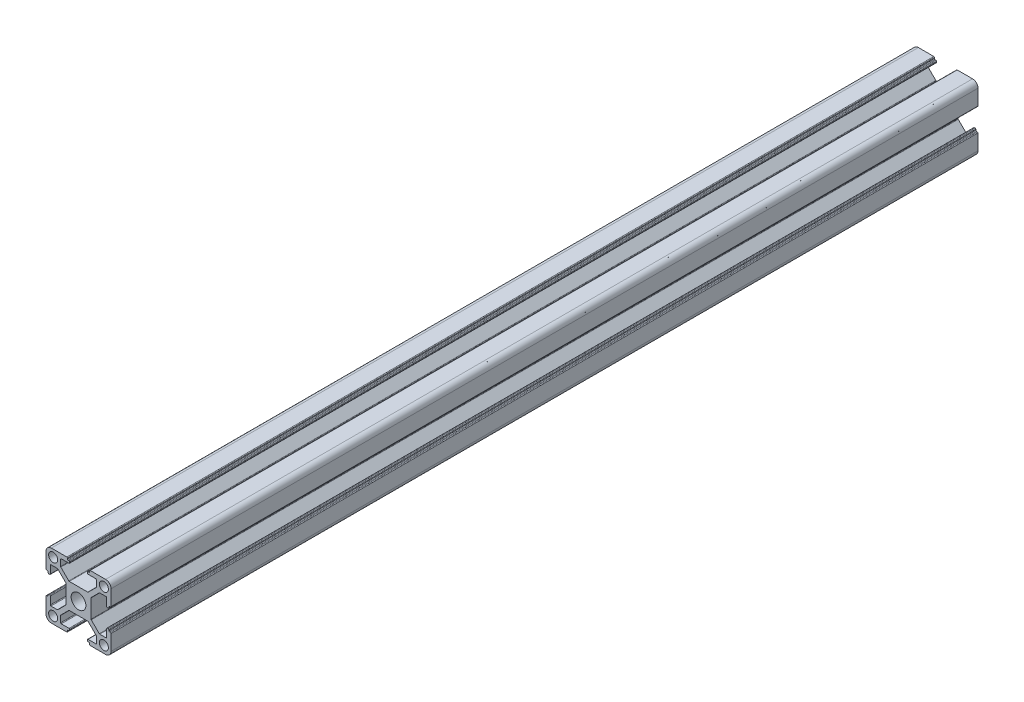
from build123d import *

# Parameters (mm, degrees)
CROQUIS1_R              = 2.1
CROQUIS1_R_2            = 3.4
SALIENTE_EXTRUIR1_DEPTH = 400


with BuildPart() as part:
    # Croquis1 → Saliente-Extruir1 (new body)
    with BuildSketch(Plane(origin=(0, 0, -50), x_dir=(-1, 0, 0), z_dir=(0, 0, -1))):
        with BuildLine():
            Line((14.7, -5.1), (14.3, -5.1))
            ThreePointArc((14.3, -5.1), (14.087867966, -5.012132034), (14, -4.8))
            Line((14, -4.8), (14, -4.4))
            ThreePointArc((14, -4.4), (13.912132034, -4.187867966), (13.7, -4.1))
            Line((13.7, -4.1), (13.3, -4.1))
            ThreePointArc((13.3, -4.1), (13.087867966, -4.187867966), (13, -4.4))
            Line((13, -4.4), (13, -7.95))
            ThreePointArc((13, -7.95), (12.912132034, -8.162132034), (12.7, -8.25))
            Line((12.7, -8.25), (9.789264108, -8.25))
            ThreePointArc((9.789264108, -8.25), (9.674477865, -8.22717164), (9.577160832, -8.162160788))
            Line((9.577160832, -8.162160788), (5.887896723, -4.473896751))
            ThreePointArc((5.887896723, -4.473896751), (5.822843922, -4.376559778), (5.8, -4.261735963))
            Line((5.8, -4.261735963), (5.8, 4.260735931))
            ThreePointArc((5.8, 4.260735931), (5.82283614, 4.375540961), (5.887867966, 4.472867966))
            Line((5.887867966, 4.472867966), (9.577132034, 8.162132034))
            ThreePointArc((9.577132034, 8.162132034), (9.674459039, 8.22716386), (9.789264069, 8.25))
            Line((9.789264069, 8.25), (12.7, 8.25))
            ThreePointArc((12.7, 8.25), (12.912132034, 8.162132034), (13, 7.95))
            Line((13, 7.95), (13, 4.4))
            ThreePointArc((13, 4.4), (13.087867966, 4.187867966), (13.3, 4.1))
            Line((13.3, 4.1), (13.7, 4.1))
            ThreePointArc((13.7, 4.1), (13.912132034, 4.187867966), (14, 4.4))
            Line((14, 4.4), (14, 4.8))
            ThreePointArc((14, 4.8), (14.087867966, 5.012132034), (14.3, 5.1))
            Line((14.3, 5.1), (14.7, 5.1))
            ThreePointArc((14.7, 5.1), (14.912132034, 5.187867966), (15, 5.4))
            Line((15, 5.4), (15, 12.5))
            ThreePointArc((15, 12.5), (14.267766953, 14.267766953), (12.5, 15))
            Line((12.5, 15), (5.4, 15))
            ThreePointArc((5.4, 15), (5.187867966, 14.912132034), (5.1, 14.7))
            Line((5.1, 14.7), (5.1, 14.3))
            ThreePointArc((5.1, 14.3), (5.012132034, 14.087867966), (4.8, 14))
            Line((4.8, 14), (4.4, 14))
            ThreePointArc((4.4, 14), (4.187867966, 13.912132034), (4.1, 13.7))
            Line((4.1, 13.7), (4.1, 13.3))
            ThreePointArc((4.1, 13.3), (4.187867966, 13.087867966), (4.4, 13))
            Line((4.4, 13), (7.95, 13))
            ThreePointArc((7.95, 13), (8.162132034, 12.912132034), (8.25, 12.7))
            Line((8.25, 12.7), (8.25, 9.788264069))
            ThreePointArc((8.25, 9.788264069), (8.22716386, 9.673459039), (8.162132034, 9.576132034))
            Line((8.162132034, 9.576132034), (4.473867966, 5.887867966))
            ThreePointArc((4.473867966, 5.887867966), (4.376540961, 5.82283614), (4.261735931, 5.8))
            Line((4.261735931, 5.8), (-4.260735892, 5.8))
            ThreePointArc((-4.260735892, 5.8), (-4.375522135, 5.82282836), (-4.472839168, 5.887839212))
            Line((-4.472839168, 5.887839212), (-8.162103277, 9.576103249))
            ThreePointArc((-8.162103277, 9.576103249), (-8.227156078, 9.673440222), (-8.25, 9.788264037))
            Line((-8.25, 9.788264037), (-8.25, 12.7))
            ThreePointArc((-8.25, 12.7), (-8.162132034, 12.912132034), (-7.95, 13))
            Line((-7.95, 13), (-4.4, 13))
            ThreePointArc((-4.4, 13), (-4.187867966, 13.087867966), (-4.1, 13.3))
            Line((-4.1, 13.3), (-4.1, 13.7))
            ThreePointArc((-4.1, 13.7), (-4.187867966, 13.912132034), (-4.4, 14))
            Line((-4.4, 14), (-4.8, 14))
            ThreePointArc((-4.8, 14), (-5.012132034, 14.087867966), (-5.1, 14.3))
            Line((-5.1, 14.3), (-5.1, 14.7))
            ThreePointArc((-5.1, 14.7), (-5.187867966, 14.912132034), (-5.4, 15))
            Line((-5.4, 15), (-12.5, 15))
            ThreePointArc((-12.5, 15), (-14.267766953, 14.267766953), (-15, 12.5))
            Line((-15, 12.5), (-15, 5.4))
            ThreePointArc((-15, 5.4), (-14.912132034, 5.187867966), (-14.7, 5.1))
            Line((-14.7, 5.1), (-14.3, 5.1))
            ThreePointArc((-14.3, 5.1), (-14.087867966, 5.012132034), (-14, 4.8))
            Line((-14, 4.8), (-14, 4.4))
            ThreePointArc((-14, 4.4), (-13.912132034, 4.187867966), (-13.7, 4.1))
            Line((-13.7, 4.1), (-13.3, 4.1))
            ThreePointArc((-13.3, 4.1), (-13.087867966, 4.187867966), (-13, 4.4))
            Line((-13, 4.4), (-13, 7.95))
            ThreePointArc((-13, 7.95), (-12.912132034, 8.162132034), (-12.7, 8.25))
            Line((-12.7, 8.25), (-9.788264037, 8.25))
            ThreePointArc((-9.788264037, 8.25), (-9.673440222, 8.227156078), (-9.576103249, 8.162103277))
            Line((-9.576103249, 8.162103277), (-5.887839212, 4.472839168))
            ThreePointArc((-5.887839212, 4.472839168), (-5.82282836, 4.375522135), (-5.8, 4.260735892))
            Line((-5.8, 4.260735892), (-5.8, -4.261735931))
            ThreePointArc((-5.8, -4.261735931), (-5.82283614, -4.376540961), (-5.887867966, -4.473867966))
            Line((-5.887867966, -4.473867966), (-9.576132034, -8.162132034))
            ThreePointArc((-9.576132034, -8.162132034), (-9.673459039, -8.22716386), (-9.788264069, -8.25))
            Line((-9.788264069, -8.25), (-12.7, -8.25))
            ThreePointArc((-12.7, -8.25), (-12.912132034, -8.162132034), (-13, -7.95))
            Line((-13, -7.95), (-13, -4.4))
            ThreePointArc((-13, -4.4), (-13.087867966, -4.187867966), (-13.3, -4.1))
            Line((-13.3, -4.1), (-13.7, -4.1))
            ThreePointArc((-13.7, -4.1), (-13.912132034, -4.187867966), (-14, -4.4))
            Line((-14, -4.4), (-14, -4.8))
            ThreePointArc((-14, -4.8), (-14.087867966, -5.012132034), (-14.3, -5.1))
            Line((-14.3, -5.1), (-14.7, -5.1))
            ThreePointArc((-14.7, -5.1), (-14.912132034, -5.187867966), (-15, -5.4))
            Line((-15, -5.4), (-15, -12.5))
            ThreePointArc((-15, -12.5), (-14.267766953, -14.267766953), (-12.5, -15))
            Line((-12.5, -15), (-5.4, -15))
            ThreePointArc((-5.4, -15), (-5.187867966, -14.912132034), (-5.1, -14.7))
            Line((-5.1, -14.7), (-5.1, -14.3))
            ThreePointArc((-5.1, -14.3), (-5.012132034, -14.087867966), (-4.8, -14))
            Line((-4.8, -14), (-4.4, -14))
            ThreePointArc((-4.4, -14), (-4.187867966, -13.912132034), (-4.1, -13.7))
            Line((-4.1, -13.7), (-4.1, -13.3))
            ThreePointArc((-4.1, -13.3), (-4.187867966, -13.087867966), (-4.4, -13))
            Line((-4.4, -13), (-7.95, -13))
            ThreePointArc((-7.95, -13), (-8.162132034, -12.912132034), (-8.25, -12.7))
            Line((-8.25, -12.7), (-8.25, -9.789264069))
            ThreePointArc((-8.25, -9.789264069), (-8.22716386, -9.674459039), (-8.162132034, -9.577132034))
            Line((-8.162132034, -9.577132034), (-4.472867966, -5.887867966))
            ThreePointArc((-4.472867966, -5.887867966), (-4.375540961, -5.82283614), (-4.260735931, -5.8))
            Line((-4.260735931, -5.8), (4.261735963, -5.8))
            ThreePointArc((4.261735963, -5.8), (4.376559778, -5.822843922), (4.473896751, -5.887896723))
            Line((4.473896751, -5.887896723), (8.162160788, -9.577160832))
            ThreePointArc((8.162160788, -9.577160832), (8.22717164, -9.674477865), (8.25, -9.789264108))
            Line((8.25, -9.789264108), (8.25, -12.7))
            ThreePointArc((8.25, -12.7), (8.162132034, -12.912132034), (7.95, -13))
            Line((7.95, -13), (4.4, -13))
            ThreePointArc((4.4, -13), (4.187867966, -13.087867966), (4.1, -13.3))
            Line((4.1, -13.3), (4.1, -13.7))
            ThreePointArc((4.1, -13.7), (4.187867966, -13.912132034), (4.4, -14))
            Line((4.4, -14), (4.8, -14))
            ThreePointArc((4.8, -14), (5.012132034, -14.087867966), (5.1, -14.3))
            Line((5.1, -14.3), (5.1, -14.7))
            ThreePointArc((5.1, -14.7), (5.187867966, -14.912132034), (5.4, -15))
            Line((5.4, -15), (12.5, -15))
            ThreePointArc((12.5, -15), (14.267766953, -14.267766953), (15, -12.5))
            Line((15, -12.5), (15, -5.4))
            ThreePointArc((15, -5.4), (14.912132034, -5.187867966), (14.7, -5.1))
        make_face()
        with Locations((-11.7, 11.7)):
            Circle(CROQUIS1_R, mode=Mode.SUBTRACT)
        with Locations((-11.7, -11.7)):
            Circle(CROQUIS1_R, mode=Mode.SUBTRACT)
        Circle(CROQUIS1_R_2, mode=Mode.SUBTRACT)
        with Locations((11.7, 11.7)):
            Circle(CROQUIS1_R, mode=Mode.SUBTRACT)
        with Locations((11.7, -11.7)):
            Circle(CROQUIS1_R, mode=Mode.SUBTRACT)
    extrude(amount=-SALIENTE_EXTRUIR1_DEPTH)


solid = part.part
